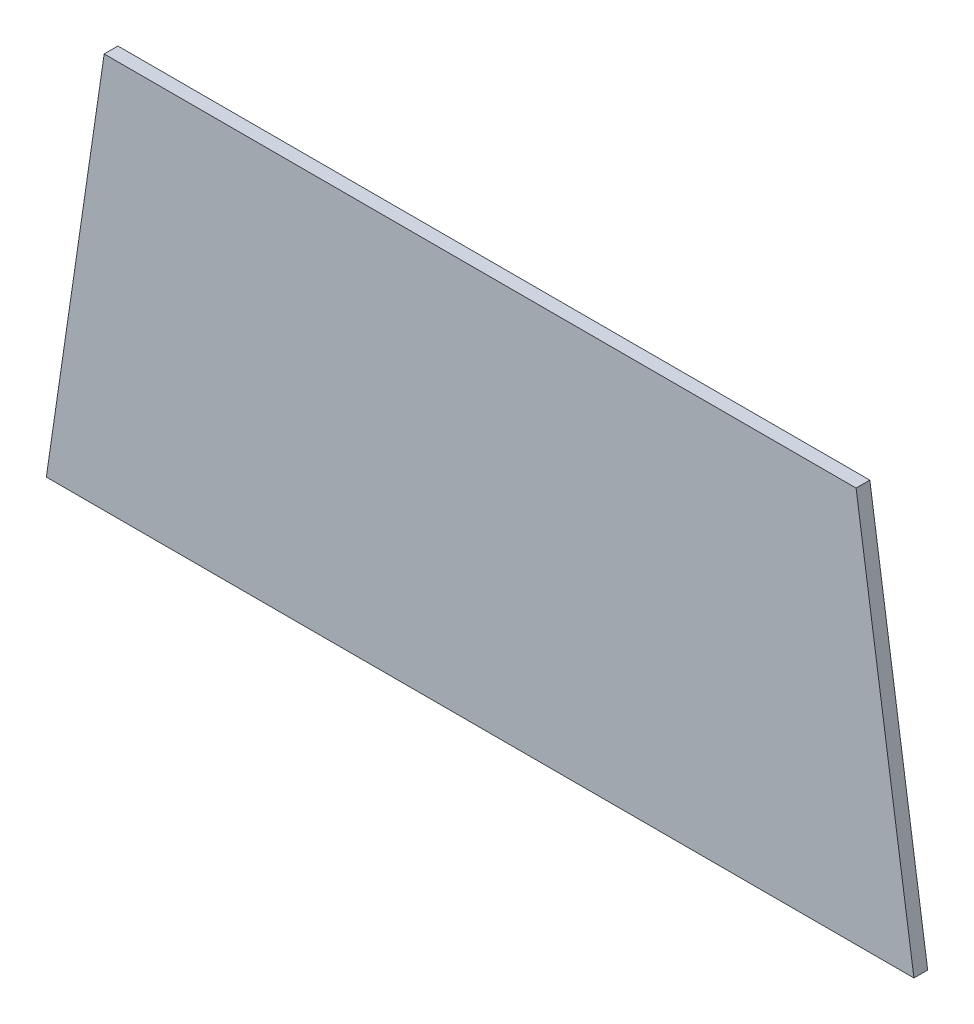
from build123d import *

# Parameters (mm, degrees)
BOSS_EXTRUDE1_DEPTH = 0.8


with BuildPart() as part:
    # Sketch1 → Boss-Extrude1 (new body)
    with BuildSketch(Plane.XY):
        Polygon((0, 0), (3.365, 23), (47.105, 23), (50.47, 0), align=None)
    extrude(amount=BOSS_EXTRUDE1_DEPTH)


solid = part.part
